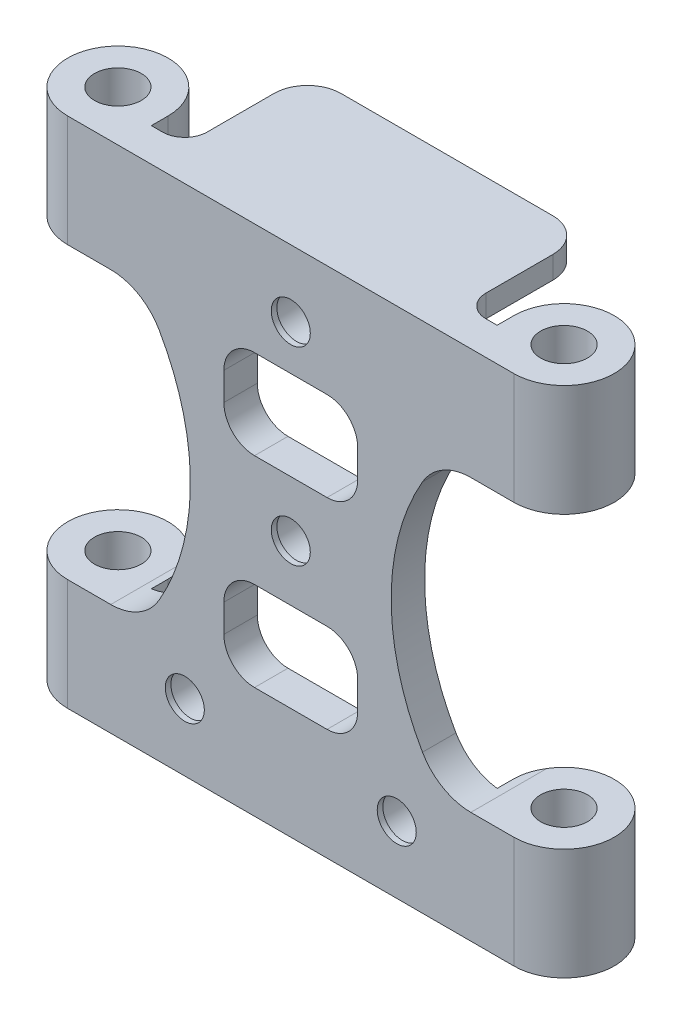
from build123d import *

# Parameters (mm, degrees)
SKETCH1_R               = 1.75
BOSS_EXTRUDE1_DEPTH     = 3
SKETCH2_R               = 2.1
BOSS_EXTRUDE2_DEPTH     = 10
SKETCH3_R               = 2.1
BOSS_EXTRUDE3_DEPTH     = 10
BOSS_EXTRUDE4_DEPTH     = 2
FILLET1_R               = 2
SKETCH6_R               = 2.1
CUT_EXTRUDE1_DEPTH      = 12
CUT_EXTRUDE1_DEPTH_BACK = 2.5
FILLET2_R               = 5


with BuildPart() as part:
    # Sketch1 → Boss-Extrude1 (new body)
    with BuildSketch(Plane.XY):
        with BuildLine():
            Line((-17, 23), (17, 23))
            Line((17, 23), (17, 13))
            Line((17, 13), (13.5, 13))
            ThreePointArc((13.5, 13), (9, 0), (13.5, -13))
            Line((13.5, -13), (17, -13))
            Line((17, -13), (17, -23))
            Line((17, -23), (-17, -23))
            Line((-17, -23), (-17, -13))
            Line((-17, -13), (-13.5, -13))
            ThreePointArc((-13.5, -13), (-9, 0), (-13.5, 13))
            Line((-13.5, 13), (-17, 13))
            Line((-17, 13), (-17, 23))
        make_face()
        Circle(SKETCH1_R, mode=Mode.SUBTRACT)
        with Locations((0, 17)):
            Circle(SKETCH1_R, mode=Mode.SUBTRACT)
        with Locations((-9.5, -17)):
            Circle(SKETCH1_R, mode=Mode.SUBTRACT)
        with Locations((9.5, -17)):
            Circle(SKETCH1_R, mode=Mode.SUBTRACT)
        with BuildLine():
            Line((-3.25, 13), (3.25, 13))
            ThreePointArc((3.25, 13), (5.194543648, 12.194543648), (6, 10.25))
            Line((6, 10.25), (6, 7.75))
            ThreePointArc((6, 7.75), (5.194543648, 5.805456352), (3.25, 5))
            Line((3.25, 5), (-3.25, 5))
            ThreePointArc((-3.25, 5), (-5.194543648, 5.805456352), (-6, 7.75))
            Line((-6, 7.75), (-6, 10.25))
            ThreePointArc((-6, 10.25), (-5.194543648, 12.194543648), (-3.25, 13))
        make_face(mode=Mode.SUBTRACT)
        with BuildLine():
            Line((-3.25, -5), (3.25, -5))
            ThreePointArc((3.25, -5), (5.194543648, -5.805456352), (6, -7.75))
            Line((6, -7.75), (6, -10.25))
            ThreePointArc((6, -10.25), (5.194543648, -12.194543648), (3.25, -13))
            Line((3.25, -13), (-3.25, -13))
            ThreePointArc((-3.25, -13), (-5.194543648, -12.194543648), (-6, -10.25))
            Line((-6, -10.25), (-6, -7.75))
            ThreePointArc((-6, -7.75), (-5.194543648, -5.805456352), (-3.25, -5))
        make_face(mode=Mode.SUBTRACT)
    extrude(amount=BOSS_EXTRUDE1_DEPTH)

    # Sketch2 → Boss-Extrude2 (add)
    with BuildSketch(Plane(origin=(0, 23, 0), x_dir=(1, 0, 0), z_dir=(0, 1, 0))):
        with BuildLine():
            Line((-20, -3), (-15.5, -3))
            Line((-15.5, -3), (-15.5, 1.5))
            ThreePointArc((-15.5, 1.5), (-23.181980515, 4.681980515), (-20, -3))
        make_face()
        with Locations((-20, 1.5)):
            Circle(SKETCH2_R, mode=Mode.SUBTRACT)
        with BuildLine():
            Line((20, -3), (15.5, -3))
            Line((15.5, -3), (15.5, 1.5))
            ThreePointArc((15.5, 1.5), (23.181980515, 4.681980515), (20, -3))
        make_face()
        with Locations((20, 1.5)):
            Circle(SKETCH2_R, mode=Mode.SUBTRACT)
    extrude(amount=-BOSS_EXTRUDE2_DEPTH)

    # Sketch3 → Boss-Extrude3 (add)
    with BuildSketch(Plane.XZ.offset(23)):
        with BuildLine():
            Line((-15.5, 3), (-20, 3))
            ThreePointArc((-20, 3), (-23.181980515, -4.681980515), (-15.5, -1.5))
            Line((-15.5, -1.5), (-15.5, 3))
        make_face()
        with Locations((-20, -1.5)):
            Circle(SKETCH3_R, mode=Mode.SUBTRACT)
        with BuildLine():
            Line((15.5, 3), (15.5, -1.5))
            ThreePointArc((15.5, -1.5), (23.181980515, -4.681980515), (20, 3))
            Line((20, 3), (15.5, 3))
        make_face()
        with Locations((20, -1.5)):
            Circle(SKETCH3_R, mode=Mode.SUBTRACT)
    extrude(amount=-BOSS_EXTRUDE3_DEPTH)

    # Sketch4 → Boss-Extrude4 (add)
    with BuildSketch(Plane(origin=(0, 23, 0), x_dir=(1, 0, 0), z_dir=(0, 1, 0))):
        with BuildLine():
            Line((-12.5, 0), (12.5, 0))
            Line((12.5, 0), (12.5, 8))
            ThreePointArc((12.5, 8), (11.621320344, 10.121320344), (9.5, 11))
            Line((9.5, 11), (-9.5, 11))
            ThreePointArc((-9.5, 11), (-11.621320344, 10.121320344), (-12.5, 8))
            Line((-12.5, 8), (-12.5, 0))
        make_face()
    extrude(amount=-BOSS_EXTRUDE4_DEPTH)

    # Fillet1
    fillet1_edges = [part.edges().sort_by_distance(p)[0] for p in [
        (-12.5, 22, 0),
        (0, 21, 0),
        (12.5, 22, 0),
    ]]
    fillet(fillet1_edges, radius=FILLET1_R)

    # Sketch6 → Cut-Extrude1 (cut, two sides)
    with BuildSketch(Plane(origin=(0, 0, 0), x_dir=(-1, 0, 0), z_dir=(0, 0, -1))) as cut_extrude1_sk:
        Circle(SKETCH6_R)
        with Locations((0, 17)):
            Circle(SKETCH6_R)
        with Locations((-9.5, -17)):
            Circle(SKETCH6_R)
        with Locations((9.5, -17)):
            Circle(SKETCH6_R)
    extrude(amount=CUT_EXTRUDE1_DEPTH, mode=Mode.SUBTRACT)
    extrude(cut_extrude1_sk.sketch, amount=-CUT_EXTRUDE1_DEPTH_BACK, mode=Mode.SUBTRACT)

    # Fillet2
    fillet2_edges = [part.edges().sort_by_distance(p)[0] for p in [
        (-13.5, -13, 1.5),
        (13.5, -13, 1.5),
        (-13.5, 13, 1.5),
        (13.5, 13, 1.5),
    ]]
    fillet(fillet2_edges, radius=FILLET2_R)


solid = part.part
